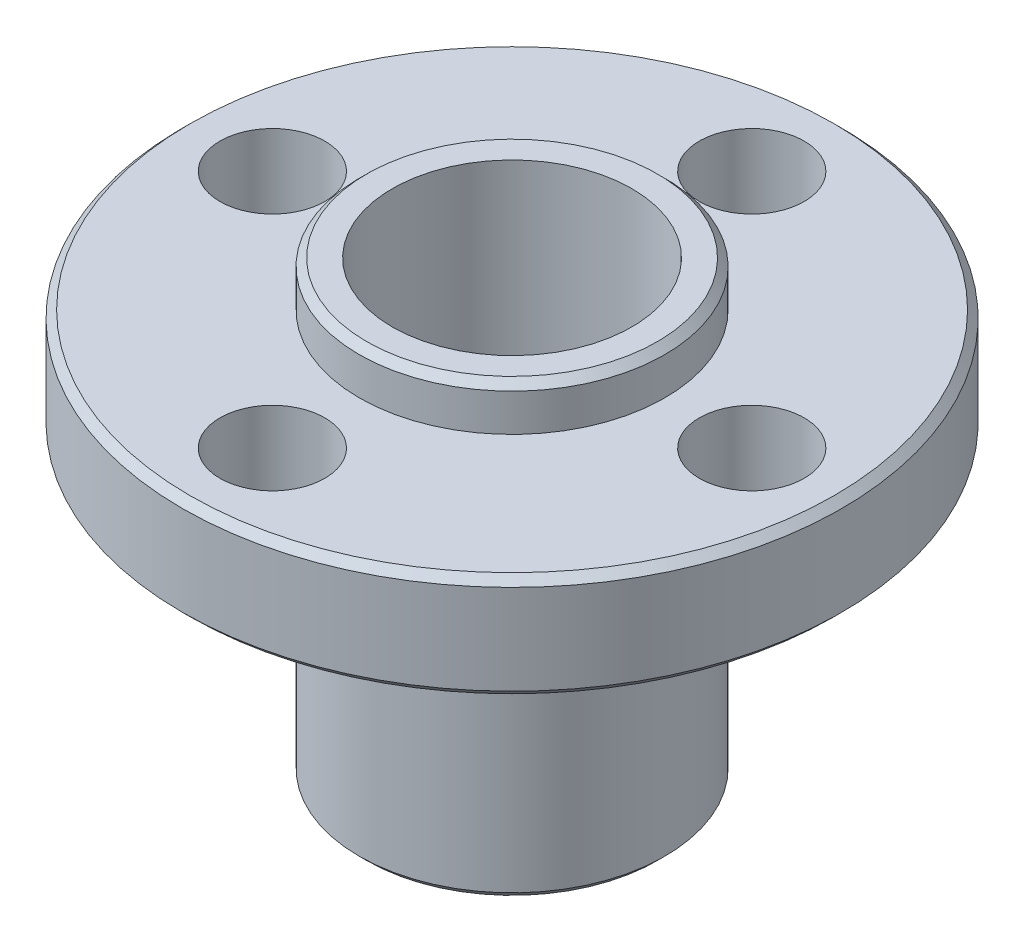
from build123d import *

# Parameters (mm, degrees)
SKETCH1_R                = 11
SKETCH1_R_2              = 5.1
SKETCH1_R_3              = 1.75
BOSS_EXTRUDE1_DEPTH      = 1.75
BOSS_EXTRUDE2_DEPTH      = 3.25
BOSS_EXTRUDE2_DEPTH_BACK = 11.75
SKETCH1_3_R              = 5.1
SKETCH1_3_R_2            = 4
CHAMFER1_SIZE            = 0.25


with BuildPart() as part:
    # Sketch1 → Boss-Extrude1 (new, symmetric)
    with BuildSketch(Plane(origin=(0, 0, 0), x_dir=(1, 0, 0), z_dir=(0, 1, 0))):
        Circle(SKETCH1_R)
        Circle(SKETCH1_R_2, mode=Mode.SUBTRACT)
        with Locations((0, 8)):
            Circle(SKETCH1_R_3, mode=Mode.SUBTRACT)
        with Locations((8, 0)):
            Circle(SKETCH1_R_3, mode=Mode.SUBTRACT)
        with Locations((0, -8)):
            Circle(SKETCH1_R_3, mode=Mode.SUBTRACT)
        with Locations((-8, 0)):
            Circle(SKETCH1_R_3, mode=Mode.SUBTRACT)
    extrude(amount=BOSS_EXTRUDE1_DEPTH, both=True)

    # Sketch1_3 → Boss-Extrude2 (add, two sides: drawn at the far end of the back side and taken through both)
    with BuildSketch(Plane(origin=(0, 0, 0), x_dir=(1, 0, 0), z_dir=(0, 1, 0)).offset(-BOSS_EXTRUDE2_DEPTH_BACK)):
        Circle(SKETCH1_3_R)
        Circle(SKETCH1_3_R_2, mode=Mode.SUBTRACT)
    extrude(amount=BOSS_EXTRUDE2_DEPTH + BOSS_EXTRUDE2_DEPTH_BACK)

    # Chamfer1
    chamfer1_edges = [part.edges().sort_by_distance(p)[0] for p in [
        (-5.1, -11.75, 0),
        (-11, -1.75, 0),
        (-11, 1.75, 0),
        (-5.1, 3.25, 0),
    ]]
    chamfer(chamfer1_edges, length=CHAMFER1_SIZE)


solid = part.part
